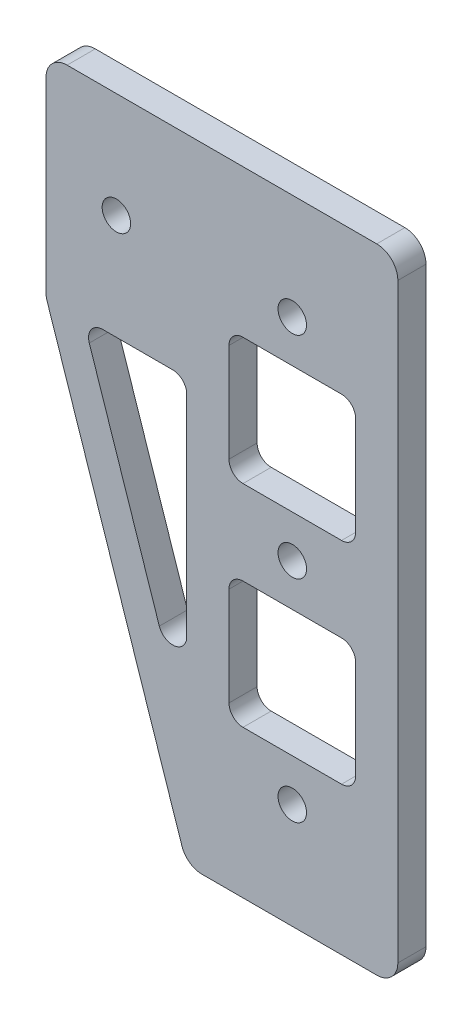
from build123d import *

# Parameters (mm, degrees)
EXTRUDE_1_DEPTH     = 4
SKETCH_2_R          = 2.025
CUT_EXTRUDE_1_DEPTH = 5
SKETCH_3_W          = 18
SKETCH_3_H          = 18
CUT_EXTRUDE_2_DEPTH = 5
FILLET_1_R          = 2
FILLET_2_R          = 3


with BuildPart() as part:
    # 草图1 → 凸台-拉伸1 (new body)
    with BuildSketch(Plane.XY):
        Polygon((0, 0), (0, -90), (-30, -90), (-50, -30), (-50, 0), align=None)
    extrude(amount=EXTRUDE_1_DEPTH)

    # 草图2 → 切除-拉伸1 (cut, through all)
    with BuildSketch(Plane.XY.offset(4)):
        with Locations((-15, -75)):
            Circle(SKETCH_2_R)
        with Locations((-15, -45)):
            Circle(SKETCH_2_R)
        with Locations((-15, -15)):
            Circle(SKETCH_2_R)
        with Locations((-40, -15)):
            Circle(SKETCH_2_R)
    extrude(amount=-CUT_EXTRUDE_1_DEPTH, mode=Mode.SUBTRACT)

    # 草图3 → 切除-拉伸2 (cut, through all)
    with BuildSketch(Plane.XY.offset(4)):
        Polygon((-44.729537233, -30), (-30, -30), (-30, -74.188611699), align=None)
        with Locations((-15, -30)):
            Rectangle(SKETCH_3_W, SKETCH_3_H)
        with Locations((-15, -60)):
            Rectangle(SKETCH_3_W, SKETCH_3_H)
    extrude(amount=-CUT_EXTRUDE_2_DEPTH, mode=Mode.SUBTRACT)

    # 圆角1
    fillet_1_edges = [part.edges().sort_by_distance(p)[0] for p in [
        (-30, -74.188611699, 2),
        (-44.729537233, -30, 2),
        (-30, -30, 2),
        (-6, -51, 2),
        (-6, -69, 2),
        (-24, -69, 2),
        (-24, -51, 2),
        (-6, -21, 2),
        (-6, -39, 2),
        (-24, -39, 2),
        (-24, -21, 2),
    ]]
    fillet(fillet_1_edges, radius=FILLET_1_R)

    # 圆角2
    fillet_2_edges = [part.edges().sort_by_distance(p)[0] for p in [
        (0, 0, 2),
        (0, -90, 2),
        (-30, -90, 2),
        (-50, -30, 2),
        (-50, 0, 2),
    ]]
    fillet(fillet_2_edges, radius=FILLET_2_R)


solid = part.part
